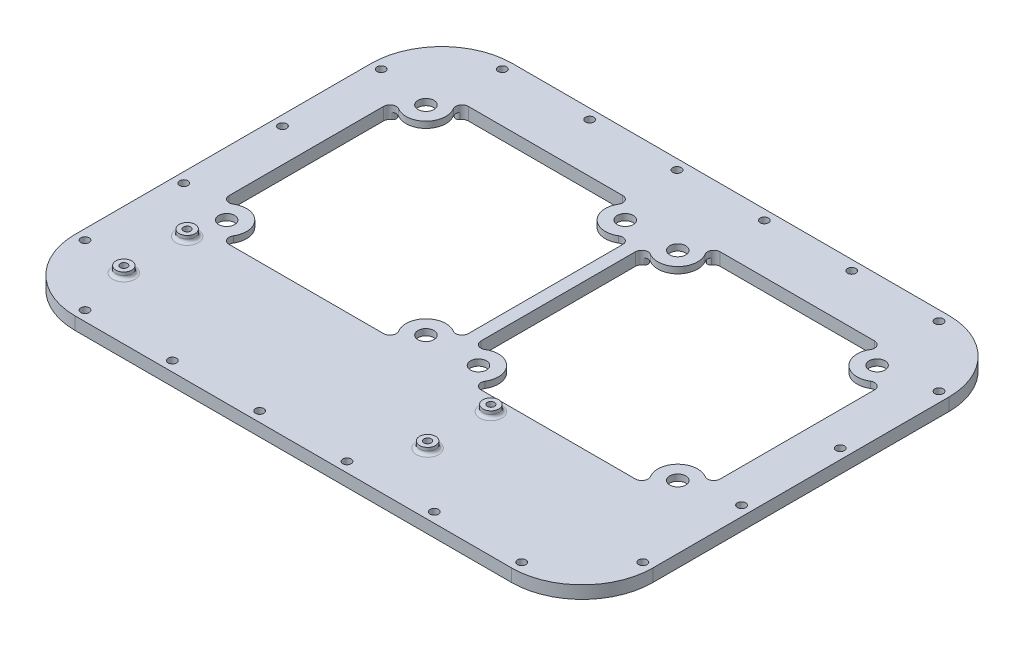
from build123d import *

# Parameters (mm, degrees)
SKETCH1_W               = 129.525
SKETCH1_H               = 66.35
SKETCH1_R               = 2
BOSS_EXTRUDE1_DEPTH     = 3.175
CUT_EXTRUDE4_DEPTH      = 4.175
CIRPATTERN1_COUNT       = 4
MIRROR1_COPY_1_DEPTH    = 4.175
MIRROR1_COPY_2_DEPTH    = 4.175
MIRROR1_COPY_3_DEPTH    = 4.175
SKETCH4_W               = 129.525
SKETCH4_H               = 3.175
BOSS_EXTRUDE2_DEPTH     = 19.05
SKETCH7_R               = 2
BOSS_EXTRUDE3_DEPTH     = 1.5875
SKETCH9_R               = 0.9
CUT_EXTRUDE5_DEPTH      = 2.5875
CUT_EXTRUDE5_DEPTH_BACK = 4.175
FILLET1_R               = 0.79375
SKETCH10_R              = 5.08
CUT_EXTRUDE6_DEPTH      = 1.5875
FILLET2_R               = 0.79375
SKETCH11_W              = 129.525
SKETCH11_H              = 85.4
BOSS_EXTRUDE4_DEPTH     = 3.175
SKETCH12_R              = 1.05
CUT_EXTRUDE7_DEPTH      = 5.7625
SKETCH13_R              = 1.875
CUT_EXTRUDE8_DEPTH      = 1.675
MIRROR3_COPY_1_SKETCH_R = 1.05
MIRROR3_COPY_1_DEPTH    = 5.7625
MIRROR3_COPY_2_SKETCH_R = 1.875
MIRROR3_COPY_2_DEPTH    = 1.675


with BuildPart() as part:
    # Sketch1 → Boss-Extrude1 (new body)
    with BuildSketch(Plane(origin=(0, 0, 0), x_dir=(1, 0, 0), z_dir=(0, 1, 0))):
        Rectangle(SKETCH1_W, SKETCH1_H)
        with Locations((-56.5875, 25)):
            Circle(SKETCH1_R, mode=Mode.SUBTRACT)
        with Locations((-6.5875, 25)):
            Circle(SKETCH1_R, mode=Mode.SUBTRACT)
        with Locations((-6.5875, -25)):
            Circle(SKETCH1_R, mode=Mode.SUBTRACT)
        with Locations((-56.5875, -25)):
            Circle(SKETCH1_R, mode=Mode.SUBTRACT)
        with Locations((6.5875, 25)):
            Circle(SKETCH1_R, mode=Mode.SUBTRACT)
        with Locations((56.5875, 25)):
            Circle(SKETCH1_R, mode=Mode.SUBTRACT)
        with Locations((56.5875, -25)):
            Circle(SKETCH1_R, mode=Mode.SUBTRACT)
        with Locations((6.5875, -25)):
            Circle(SKETCH1_R, mode=Mode.SUBTRACT)
    extrude(amount=BOSS_EXTRUDE1_DEPTH)

    # Sketch2 → Cut-Extrude4 (cut, through all)
    with BuildSketch(Plane(origin=(0, 0, 0), x_dir=(1, 0, 0), z_dir=(0, 1, 0))):
        with BuildLine():
            Line((-31.5875, 0), (-31.5875, 30))
            Line((-31.5875, 30), (-50.952786165, 30))
            ThreePointArc((-50.952786165, 30), (-52.335837888, 29.191810068), (-52.310677355, 27.590132827))
            ThreePointArc((-52.310677355, 27.590132827), (-53.051966094, 21.464466094), (-59.177632827, 20.723177355))
            ThreePointArc((-59.177632827, 20.723177355), (-60.779310068, 20.748337888), (-61.5875, 19.365286165))
            Line((-61.5875, 19.365286165), (-61.5875, 0))
            Line((-61.5875, 0), (-31.5875, 0))
        make_face()
    cut_extrude4 = extrude(amount=CUT_EXTRUDE4_DEPTH, mode=Mode.SUBTRACT)

    # CirPattern1: Cut-Extrude4 ×4 about axis
    cirpattern1_axis = Axis((-31.5875, 0, 0), (0, 1, 0))
    for i in range(1, CIRPATTERN1_COUNT):
        add(cut_extrude4.rotate(cirpattern1_axis, i * 360 / CIRPATTERN1_COUNT), mode=Mode.SUBTRACT)

    # Mirror1: Cut-Extrude4 across plane
    add(cut_extrude4.mirror(Plane(origin=(0, 0, 0), x_dir=(0, 0, 1), z_dir=(1, 0, 0))), mode=Mode.SUBTRACT)

    # Mirror1 copy 1 sketch → Mirror1 copy 1 (cut, through all)
    with BuildSketch(Plane(origin=(31.5875, 0, -31.5875), x_dir=(0, 0, -1), z_dir=(0, 1, 0))):
        with BuildLine():
            Line((-31.5875, 0), (-31.5875, -30))
            Line((-31.5875, -30), (-50.952786165, -30))
            ThreePointArc((-50.952786165, -30), (-52.335837888, -29.191810068), (-52.310677355, -27.590132827))
            ThreePointArc((-52.310677355, -27.590132827), (-53.051966094, -21.464466094), (-59.177632827, -20.723177355))
            ThreePointArc((-59.177632827, -20.723177355), (-60.779310068, -20.748337888), (-61.5875, -19.365286165))
            Line((-61.5875, -19.365286165), (-61.5875, 0))
            Line((-61.5875, 0), (-31.5875, 0))
        make_face()
    extrude(amount=MIRROR1_COPY_1_DEPTH, mode=Mode.SUBTRACT)

    # Mirror1 copy 2 sketch → Mirror1 copy 2 (cut, through all)
    with BuildSketch(Plane(origin=(63.175, 0, 0), x_dir=(1, 0, 0), z_dir=(0, 1, 0))):
        with BuildLine():
            Line((-31.5875, 0), (-31.5875, -30))
            Line((-31.5875, -30), (-50.952786165, -30))
            ThreePointArc((-50.952786165, -30), (-52.335837888, -29.191810068), (-52.310677355, -27.590132827))
            ThreePointArc((-52.310677355, -27.590132827), (-53.051966094, -21.464466094), (-59.177632827, -20.723177355))
            ThreePointArc((-59.177632827, -20.723177355), (-60.779310068, -20.748337888), (-61.5875, -19.365286165))
            Line((-61.5875, -19.365286165), (-61.5875, 0))
            Line((-61.5875, 0), (-31.5875, 0))
        make_face()
    extrude(amount=MIRROR1_COPY_2_DEPTH, mode=Mode.SUBTRACT)

    # Mirror1 copy 3 sketch → Mirror1 copy 3 (cut, through all)
    with BuildSketch(Plane(origin=(31.5875, 0, 31.5875), x_dir=(0, 0, 1), z_dir=(0, 1, 0))):
        with BuildLine():
            Line((-31.5875, 0), (-31.5875, -30))
            Line((-31.5875, -30), (-50.952786165, -30))
            ThreePointArc((-50.952786165, -30), (-52.335837888, -29.191810068), (-52.310677355, -27.590132827))
            ThreePointArc((-52.310677355, -27.590132827), (-53.051966094, -21.464466094), (-59.177632827, -20.723177355))
            ThreePointArc((-59.177632827, -20.723177355), (-60.779310068, -20.748337888), (-61.5875, -19.365286165))
            Line((-61.5875, -19.365286165), (-61.5875, 0))
            Line((-61.5875, 0), (-31.5875, 0))
        make_face()
    extrude(amount=MIRROR1_COPY_3_DEPTH, mode=Mode.SUBTRACT)

    # Sketch4 → Boss-Extrude2 (add)
    with BuildSketch(Plane.XY.offset(33.175)):
        with Locations((0, 1.5875)):
            Rectangle(SKETCH4_W, SKETCH4_H)
    extrude(amount=BOSS_EXTRUDE2_DEPTH)

    # Sketch7 → Boss-Extrude3 (add)
    with BuildSketch(Plane(origin=(0, 3.175, 0), x_dir=(1, 0, 0), z_dir=(0, 1, 0))):
        with Locations((-58, -33.5)):
            Circle(SKETCH7_R)
        with Locations((18.2, -33.5)):
            Circle(SKETCH7_R)
        with Locations((18.2, -49.375)):
            Circle(SKETCH7_R)
        with Locations((-58, -49.375)):
            Circle(SKETCH7_R)
    extrude(amount=BOSS_EXTRUDE3_DEPTH)

    # Sketch9 → Cut-Extrude5 (cut, two sides)
    with BuildSketch(Plane(origin=(0, 3.175, 0), x_dir=(1, 0, 0), z_dir=(0, 1, 0))) as cut_extrude5_sk:
        with Locations((-58, -33.5)):
            Circle(SKETCH9_R)
        with Locations((-58, -49.375)):
            Circle(SKETCH9_R)
        with Locations((18.2, -49.375)):
            Circle(SKETCH9_R)
        with Locations((18.2, -33.5)):
            Circle(SKETCH9_R)
    extrude(amount=CUT_EXTRUDE5_DEPTH, mode=Mode.SUBTRACT)
    extrude(cut_extrude5_sk.sketch, amount=-CUT_EXTRUDE5_DEPTH_BACK, mode=Mode.SUBTRACT)

    # Fillet1
    fillet1_edges = [part.edges().sort_by_distance(p)[0] for p in [
        (-60, 3.175, 33.5),
        (16.2, 3.175, 33.5),
        (16.2, 3.175, 49.375),
        (-60, 3.175, 49.375),
    ]]
    fillet(fillet1_edges, radius=FILLET1_R)

    # Sketch10 → Cut-Extrude6 (cut)
    with BuildSketch(Plane.XZ):
        with Locations((56.5875, -25)):
            Circle(SKETCH10_R)
        with Locations((56.5875, 25)):
            Circle(SKETCH10_R)
        with Locations((6.5875, 25)):
            Circle(SKETCH10_R)
        with Locations((6.5875, -25)):
            Circle(SKETCH10_R)
        with Locations((-6.5875, -25)):
            Circle(SKETCH10_R)
        with Locations((-6.5875, 25)):
            Circle(SKETCH10_R)
        with Locations((-56.5875, 25)):
            Circle(SKETCH10_R)
        with Locations((-56.5875, -25)):
            Circle(SKETCH10_R)
    extrude(amount=-CUT_EXTRUDE6_DEPTH, mode=Mode.SUBTRACT)

    # Fillet2
    fillet2_edges = [part.edges().sort_by_distance(p)[0] for p in [
        (10.690526658, 0.79375, -27.995258294),
        (3.592241706, 0.79375, 20.896973342),
        (52.484473342, 0.79375, 27.995258294),
        (59.582758294, 0.79375, -20.896973342),
        (-10.690526658, 0.79375, -27.995258294),
        (-3.592241706, 0.79375, 20.896973342),
        (-52.484473342, 0.79375, 27.995258294),
        (-59.582758294, 0.79375, -20.896973342),
        (59.582758294, 0.79375, 20.896973342),
        (10.690526658, 0.79375, 27.995258294),
        (3.592241706, 0.79375, -20.896973342),
        (-3.592241706, 0.79375, -20.896973342),
        (-10.690526658, 0.79375, 27.995258294),
        (-59.582758294, 0.79375, 20.896973342),
        (-52.484473342, 0.79375, -27.995258294),
        (52.484473342, 0.79375, -27.995258294),
    ]]
    fillet(fillet2_edges, radius=FILLET2_R)

    # Sketch11 → Boss-Extrude4 (add)
    with BuildSketch(Plane.XZ.offset(-3.175)):
        with BuildLine():
            Line((-72.46875, 47.1475), (-72.46875, -27.1475))
            ThreePointArc((-72.46875, -27.1475), (-67.284540027, -39.663290027), (-54.76875, -44.8475))
            Line((-54.76875, -44.8475), (54.76875, -44.8475))
            ThreePointArc((54.76875, -44.8475), (67.284540027, -39.663290027), (72.46875, -27.1475))
            Line((72.46875, -27.1475), (72.46875, 47.1475))
            ThreePointArc((72.46875, 47.1475), (67.284540027, 59.663290027), (54.76875, 64.8475))
            Line((54.76875, 64.8475), (-54.76875, 64.8475))
            ThreePointArc((-54.76875, 64.8475), (-67.284540027, 59.663290027), (-72.46875, 47.1475))
        make_face()
        with Locations((0, 9.525)):
            Rectangle(SKETCH11_W, SKETCH11_H, mode=Mode.SUBTRACT)
    extrude(amount=BOSS_EXTRUDE4_DEPTH)

    # Sketch12 → Cut-Extrude7 (cut, through all)
    with BuildSketch(Plane.XZ):
        with Locations((54.76875, -42.3475)):
            Circle(SKETCH12_R)
        with Locations((32.86125, -42.3475)):
            Circle(SKETCH12_R)
        with Locations((10.95375, -42.3475)):
            Circle(SKETCH12_R)
        with Locations((69.96875, -27.1475)):
            Circle(SKETCH12_R)
        with Locations((69.96875, -2.3825)):
            Circle(SKETCH12_R)
    cut_extrude7 = extrude(amount=-CUT_EXTRUDE7_DEPTH, mode=Mode.SUBTRACT)

    # Sketch13 → Cut-Extrude8 (cut)
    with BuildSketch(Plane.XZ):
        with Locations((69.96875, -27.1475)):
            Circle(SKETCH13_R)
        with Locations((69.96875, -2.3825)):
            Circle(SKETCH13_R)
        with Locations((54.76875, -42.3475)):
            Circle(SKETCH13_R)
        with Locations((32.86125, -42.3475)):
            Circle(SKETCH13_R)
        with Locations((10.95375, -42.3475)):
            Circle(SKETCH13_R)
    cut_extrude8 = extrude(amount=-CUT_EXTRUDE8_DEPTH, mode=Mode.SUBTRACT)

    # Mirror2: Cut-Extrude7, Cut-Extrude8 across plane
    add(cut_extrude7.mirror(Plane(origin=(0, 0, 10), x_dir=(1, 0, 0), z_dir=(0, 0, -1))), mode=Mode.SUBTRACT)
    add(cut_extrude8.mirror(Plane(origin=(0, 0, 10), x_dir=(1, 0, 0), z_dir=(0, 0, -1))), mode=Mode.SUBTRACT)

    # Mirror3: Cut-Extrude7, Cut-Extrude8 across plane
    add(cut_extrude7.mirror(Plane(origin=(0, 0, 0), x_dir=(0, 0, 1), z_dir=(1, 0, 0))), mode=Mode.SUBTRACT)
    add(cut_extrude8.mirror(Plane(origin=(0, 0, 0), x_dir=(0, 0, 1), z_dir=(1, 0, 0))), mode=Mode.SUBTRACT)

    # Mirror3 copy 1 sketch → Mirror3 copy 1 (cut, through all)
    with BuildSketch(Plane(origin=(0, 0, 20), x_dir=(-1, 0, 0), z_dir=(0, -1, 0))):
        with Locations((54.76875, -42.3475)):
            Circle(MIRROR3_COPY_1_SKETCH_R)
        with Locations((32.86125, -42.3475)):
            Circle(MIRROR3_COPY_1_SKETCH_R)
        with Locations((10.95375, -42.3475)):
            Circle(MIRROR3_COPY_1_SKETCH_R)
        with Locations((69.96875, -27.1475)):
            Circle(MIRROR3_COPY_1_SKETCH_R)
        with Locations((69.96875, -2.3825)):
            Circle(MIRROR3_COPY_1_SKETCH_R)
    extrude(amount=-MIRROR3_COPY_1_DEPTH, mode=Mode.SUBTRACT)

    # Mirror3 copy 2 sketch → Mirror3 copy 2 (cut)
    with BuildSketch(Plane(origin=(0, 0, 20), x_dir=(-1, 0, 0), z_dir=(0, -1, 0))):
        with Locations((69.96875, -27.1475)):
            Circle(MIRROR3_COPY_2_SKETCH_R)
        with Locations((69.96875, -2.3825)):
            Circle(MIRROR3_COPY_2_SKETCH_R)
        with Locations((54.76875, -42.3475)):
            Circle(MIRROR3_COPY_2_SKETCH_R)
        with Locations((32.86125, -42.3475)):
            Circle(MIRROR3_COPY_2_SKETCH_R)
        with Locations((10.95375, -42.3475)):
            Circle(MIRROR3_COPY_2_SKETCH_R)
    extrude(amount=-MIRROR3_COPY_2_DEPTH, mode=Mode.SUBTRACT)


solid = part.part
